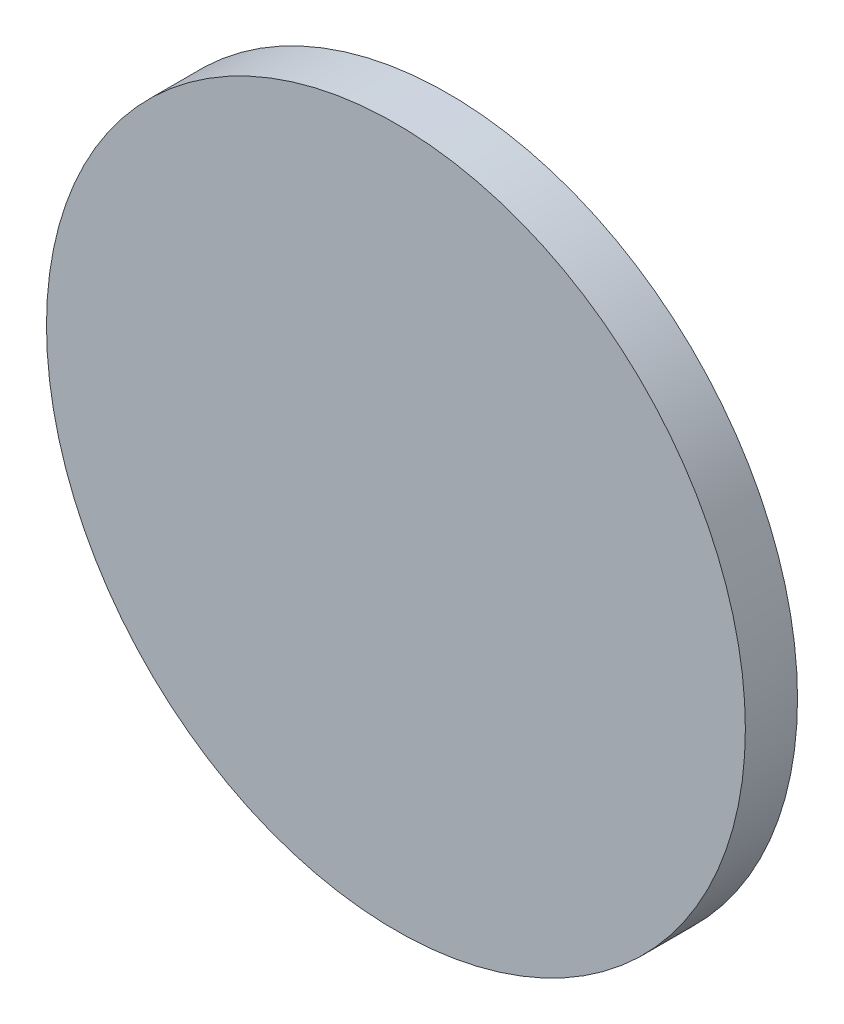
from build123d import *

# Parameters (mm, degrees)
SKETCH1_R           = 6.7
BOSS_EXTRUDE1_DEPTH = 1


with BuildPart() as part:
    # Sketch1 → Boss-Extrude1 (new body)
    with BuildSketch(Plane.XY):
        Circle(SKETCH1_R)
    extrude(amount=BOSS_EXTRUDE1_DEPTH)


solid = part.part
